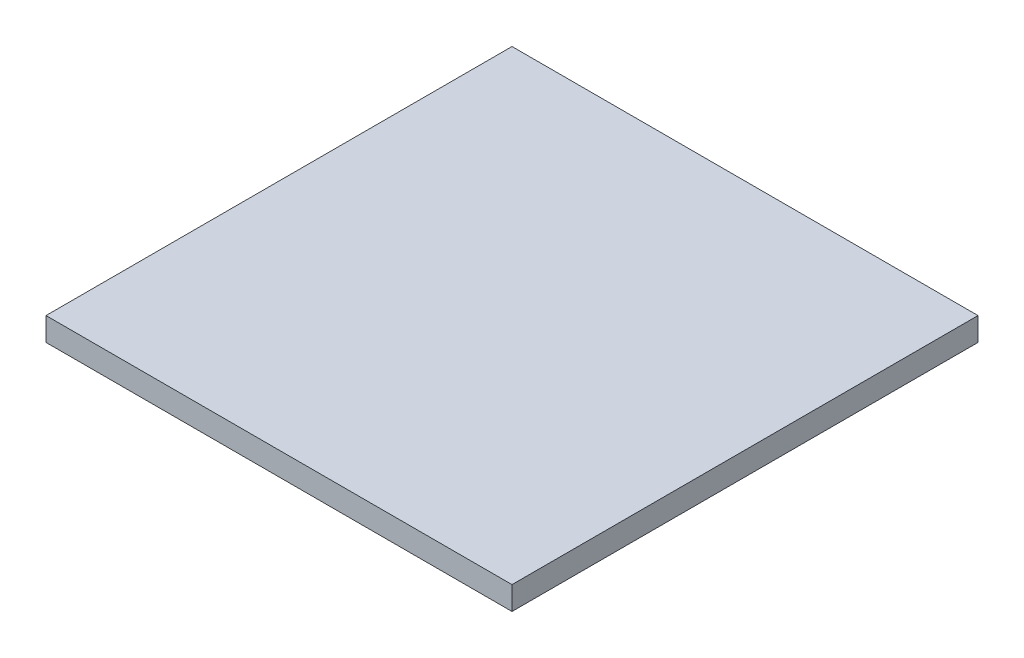
from build123d import *

# Parameters (mm, degrees)
SKETCH_1_W      = 100
SKETCH_1_H      = 100
EXTRUDE_1_DEPTH = 5


with BuildPart() as part:
    # Эскиз1 → Бобышка-Вытянуть1 (new body)
    with BuildSketch(Plane(origin=(0, 0, 0), x_dir=(1, 0, 0), z_dir=(0, 1, 0))):
        with Locations((-21.219512195, -13.170731707)):
            Rectangle(SKETCH_1_W, SKETCH_1_H)
    extrude(amount=EXTRUDE_1_DEPTH)


solid = part.part
